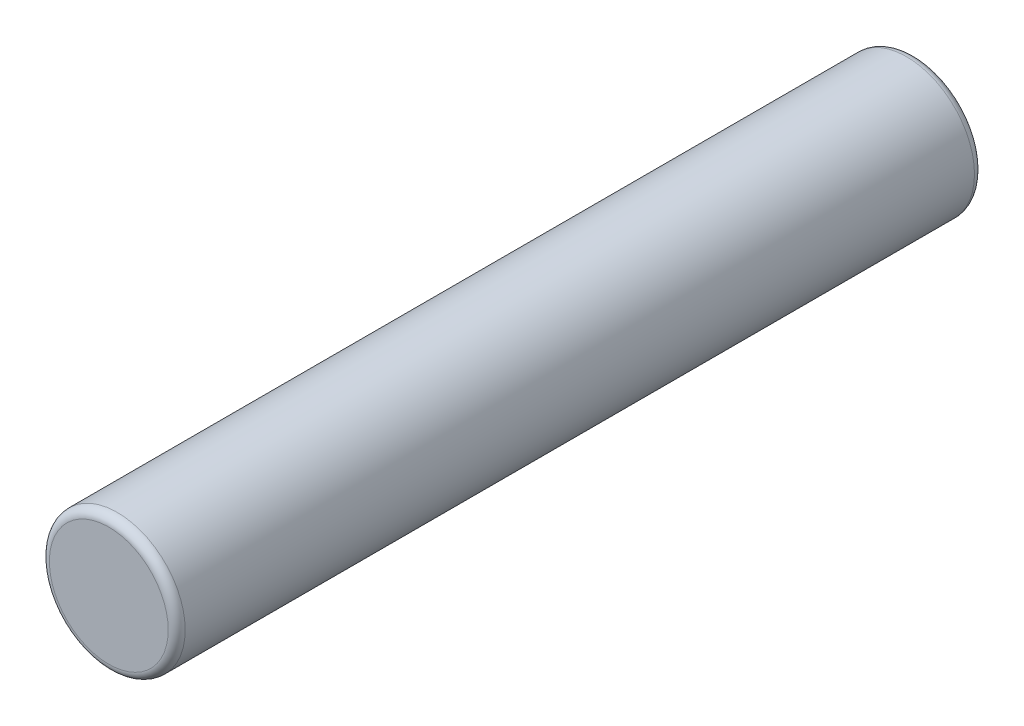
from build123d import *

# Parameters (mm, degrees)
SKETCH1_R           = 0.8
BOSS_EXTRUDE2_DEPTH = 9.5
FILLET2_R           = 0.1


with BuildPart() as part:
    # Sketch1 → Boss-Extrude2 (new body)
    with BuildSketch(Plane.XY):
        Circle(SKETCH1_R)
    extrude(amount=BOSS_EXTRUDE2_DEPTH)

    # Fillet2
    fillet2_edges = [part.edges().sort_by_distance(p)[0] for p in [
        (-0.8, 0, 0),
        (-0.8, 0, 9.5),
    ]]
    fillet(fillet2_edges, radius=FILLET2_R)


solid = part.part
